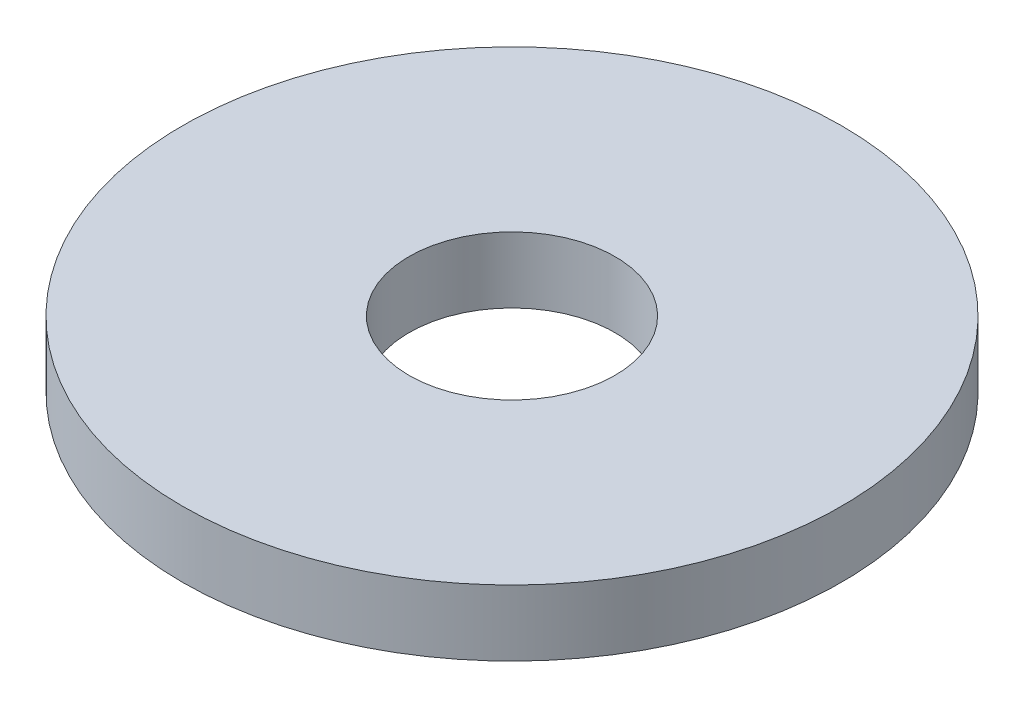
from build123d import *

# Parameters (mm, degrees)
SKETCH1_R      = 15.875
SKETCH1_R_2    = 4.9609375
EXTRUDE1_DEPTH = 1.5875


with BuildPart() as part:
    # Sketch1 → Extrude1 (new body, symmetric)
    with BuildSketch(Plane(origin=(0, 0, 0), x_dir=(1, 0, 0), z_dir=(0, 1, 0))):
        Circle(SKETCH1_R)
        Circle(SKETCH1_R_2, mode=Mode.SUBTRACT)
    extrude(amount=EXTRUDE1_DEPTH, both=True)


solid = part.part
